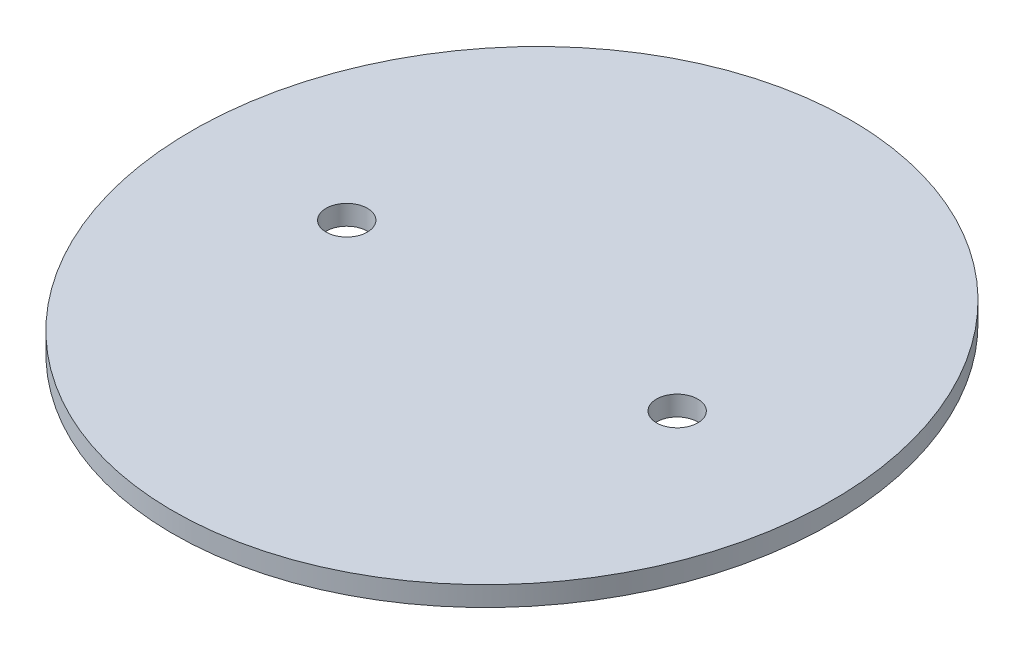
from build123d import *

# Parameters (mm, degrees)
SKETCH1_RX          = 102.5
SKETCH1_RY          = 96.9
SKETCH1_R           = 6.25
BOSS_EXTRUDE1_DEPTH = 6


with BuildPart() as part:
    # Sketch1 → Boss-Extrude1 (new body)
    with BuildSketch(Plane(origin=(0, 0, 0), x_dir=(1, 0, 0), z_dir=(0, 1, 0))):
        with Locations(Location((0, 0), (0, 0, 90))):
            Ellipse(SKETCH1_RX, SKETCH1_RY)
        with Locations((-50, 0)):
            Circle(SKETCH1_R, mode=Mode.SUBTRACT)
        with Locations((50, 0)):
            Circle(SKETCH1_R, mode=Mode.SUBTRACT)
    extrude(amount=BOSS_EXTRUDE1_DEPTH)


solid = part.part
